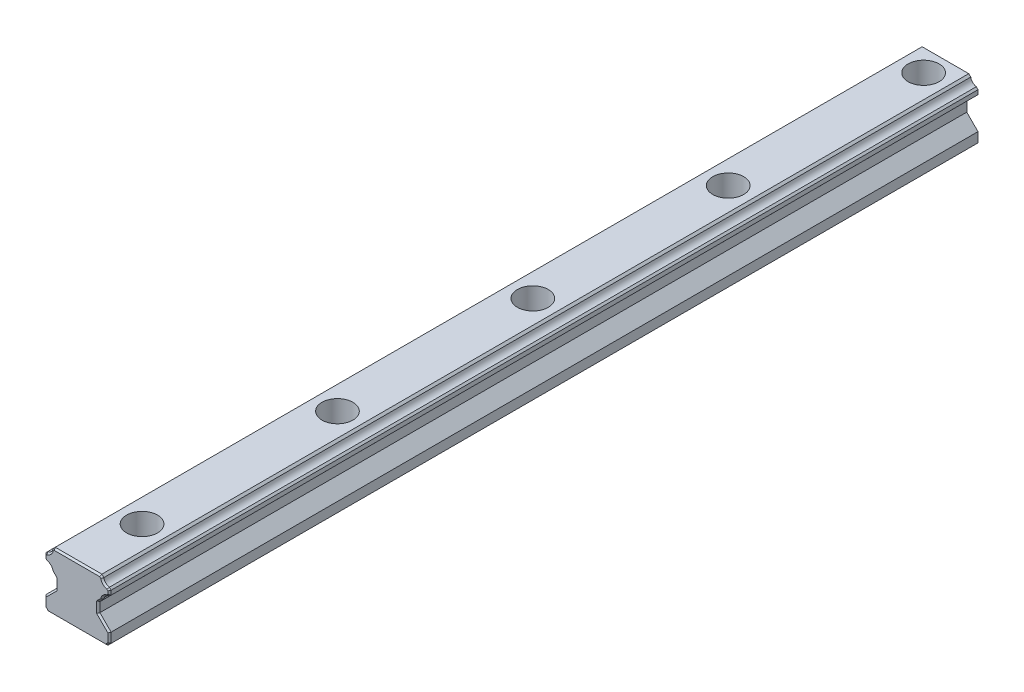
from build123d import *

# Parameters (mm, degrees)
BOSS_EXTRUDE1_DEPTH      = 140
BOSS_EXTRUDE1_DEPTH_BACK = 140
LPATTERN2_COUNT          = 5
LPATTERN2_PITCH          = 60
CHAMFER1_SIZE            = 0.5
CUT_EXTRUDE1_DEPTH       = 1
CUT_EXTRUDE1_DEPTH_BACK  = 19


with BuildPart() as part:
    # Sketch3 → Boss-Extrude1 (new body, two sides)
    with BuildSketch(Plane.XY) as boss_extrude1_sk:
        with BuildLine():
            Line((3, 9), (-3, 9))
            Line((-3, 9), (-7.160036564, 9))
            Line((-7.160036564, 9), (-7.767930373, 8.392105714))
            ThreePointArc((-7.767930373, 8.392105714), (-8.344874488, 7.264307267), (-9.472673258, 6.687363783))
            Line((-9.472673258, 6.687363783), (-10, 6.160037041))
            Line((-10, 6.160037041), (-10, 4.82918644))
            Line((-10, 4.82918644), (-9.472673258, 4.314376637))
            ThreePointArc((-9.472673258, 4.314376637), (-8.341068744, 3.731631743), (-7.767930373, 2.595131504))
            Line((-7.767930373, 2.595131504), (-6.550048828, 1.379235268))
            Line((-6.550048828, 1.379235268), (-6.550048828, -1.550048828))
            Line((-6.550048828, -1.550048828), (-10, -4.999922752))
            Line((-10, -4.999922752), (-10, -8))
            Line((-10, -8), (-9, -9))
            Line((-9, -9), (0, -9))
            Line((0, -9), (9, -9))
            Line((9, -9), (10, -8))
            Line((10, -8), (10, -4.999922752))
            Line((10, -4.999922752), (6.550048828, -1.550048828))
            Line((6.550048828, -1.550048828), (6.550048828, 1.379235268))
            Line((6.550048828, 1.379235268), (7.767930373, 2.595131504))
            ThreePointArc((7.767930373, 2.595131504), (8.341068744, 3.731631743), (9.472673258, 4.314376637))
            Line((9.472673258, 4.314376637), (10, 4.82918644))
            Line((10, 4.82918644), (10, 6.160037041))
            Line((10, 6.160037041), (9.472673258, 6.687363783))
            ThreePointArc((9.472673258, 6.687363783), (8.344874488, 7.264307267), (7.767930373, 8.392105714))
            Line((7.767930373, 8.392105714), (7.160036564, 9))
            Line((7.160036564, 9), (3, 9))
        make_face()
    extrude(amount=BOSS_EXTRUDE1_DEPTH)
    extrude(boss_extrude1_sk.sketch, amount=-BOSS_EXTRUDE1_DEPTH_BACK)

    # Sketch4 → Cut-Revolve1 (revolve, cut)
    with BuildSketch(Plane(origin=(0, 0, 0), x_dir=(0, 0, -1), z_dir=(1, 0, 0))):
        Polygon((-115.25, 9), (-120, 9), (-120, -9), (-117, -9), (-117, 0.5), (-115.25, 0.5), align=None)
    cut_revolve1 = revolve(axis=Axis((0, 9, 120), (0, -1, 0)), mode=Mode.SUBTRACT)

    # LPattern2: Cut-Revolve1 ×5
    with Locations(*[(0, 0, -i * LPATTERN2_PITCH) for i in range(1, LPATTERN2_COUNT)]):
        add(cut_revolve1, mode=Mode.SUBTRACT)

    # Chamfer1
    chamfer1_edges = [part.edges().sort_by_distance(p)[0] for p in [
        (-6.550048828, -0.08540678, 140),
        (-8.275024414, -3.27498579, 140),
        (-10, -6.499961376, 140),
        (-9.5, -8.5, 140),
        (0, -9, 140),
        (9.5, -8.5, 140),
        (10, -6.499961376, 140),
        (8.275024414, -3.27498579, 140),
        (6.550048828, -0.08540678, 140),
        (-8.341068744, 3.731631743, 140),
        (7.158989601, 1.987183386, 140),
        (8.341068744, 3.731631743, 140),
        (9.736336629, 4.571781538, 140),
        (-9.736336629, 4.571781538, -140),
        (-10, 5.49461174, -140),
        (10, 5.49461174, 140),
        (-9.736336629, 6.423700412, -140),
        (-7.463983469, 8.696052857, -140),
        (0, 9, -140),
        (7.463983469, 8.696052857, -140),
        (9.736336629, 6.423700412, -140),
        (10, 5.49461174, -140),
        (9.736336629, 6.423700412, 140),
        (9.736336629, 4.571781538, -140),
        (7.158989601, 1.987183386, -140),
        (6.550048828, -0.08540678, -140),
        (8.275024414, -3.27498579, -140),
        (10, -6.499961376, -140),
        (9.5, -8.5, -140),
        (0, -9, -140),
        (8.344874488, 7.264307267, 140),
        (-9.5, -8.5, -140),
        (-10, -6.499961376, -140),
        (-8.275024414, -3.27498579, -140),
        (-6.550048828, -0.08540678, -140),
        (-7.158989601, 1.987183386, -140),
        (-8.341068744, 3.731631743, -140),
        (-8.344874488, 7.264307267, -140),
        (8.344874488, 7.264307267, -140),
        (8.341068744, 3.731631743, -140),
        (7.463983469, 8.696052857, 140),
        (0, 9, 140),
        (-7.463983469, 8.696052857, 140),
        (-8.344874488, 7.264307267, 140),
        (-7.158989601, 1.987183386, 140),
        (-9.736336629, 6.423700412, 140),
        (-10, 5.49461174, 140),
        (-9.736336629, 4.571781538, 140),
    ]]
    chamfer(chamfer1_edges, length=CHAMFER1_SIZE)

    # Sketch7 → Cut-Extrude1 (cut, two sides)
    with BuildSketch(Plane.XZ.offset(9)) as cut_extrude1_sk:
        Polygon((563.970585521, -126.7), (15.689992686, -126.7), (-26.160878802, -126.7), (-574.441471637, -126.7), (-574.441471637, -1223.26118567), (563.970585521, -1223.26118567), align=None)
    extrude(amount=CUT_EXTRUDE1_DEPTH, mode=Mode.SUBTRACT)
    extrude(cut_extrude1_sk.sketch, amount=-CUT_EXTRUDE1_DEPTH_BACK, mode=Mode.SUBTRACT)


solid = part.part
